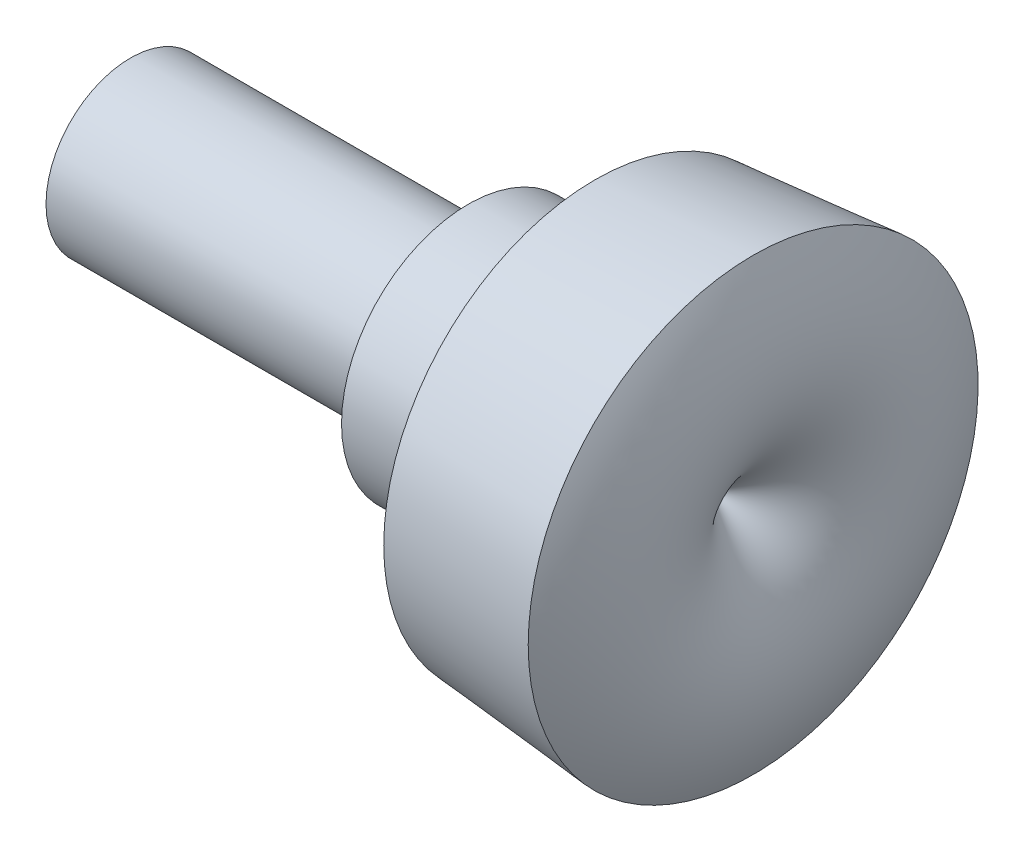
from build123d import *


with BuildPart() as part:
    # Sketch2 → Revolve1 (revolve)
    with BuildSketch(Plane.XY):
        with BuildLine():
            Line((0, 0), (0, 2))
            Line((0, 2), (8, 2))
            Line((8, 2), (8, 3))
            Line((8, 3), (11, 3))
            Line((11, 3), (11, 5))
            Line((11, 5), (14.75, 5.328082488))
            add(Edge.make_bspline(
                [(14.75, 5.328082488), (16.478433804, 2.101172747), (13.75, 0)],
                knots=[0, 0, 0, 1, 1, 1], degree=2))
            Line((13.75, 0), (0, 0))
        make_face()
    revolve(axis=Axis((0, 0, 0), (1, 0, 0)))


solid = part.part
